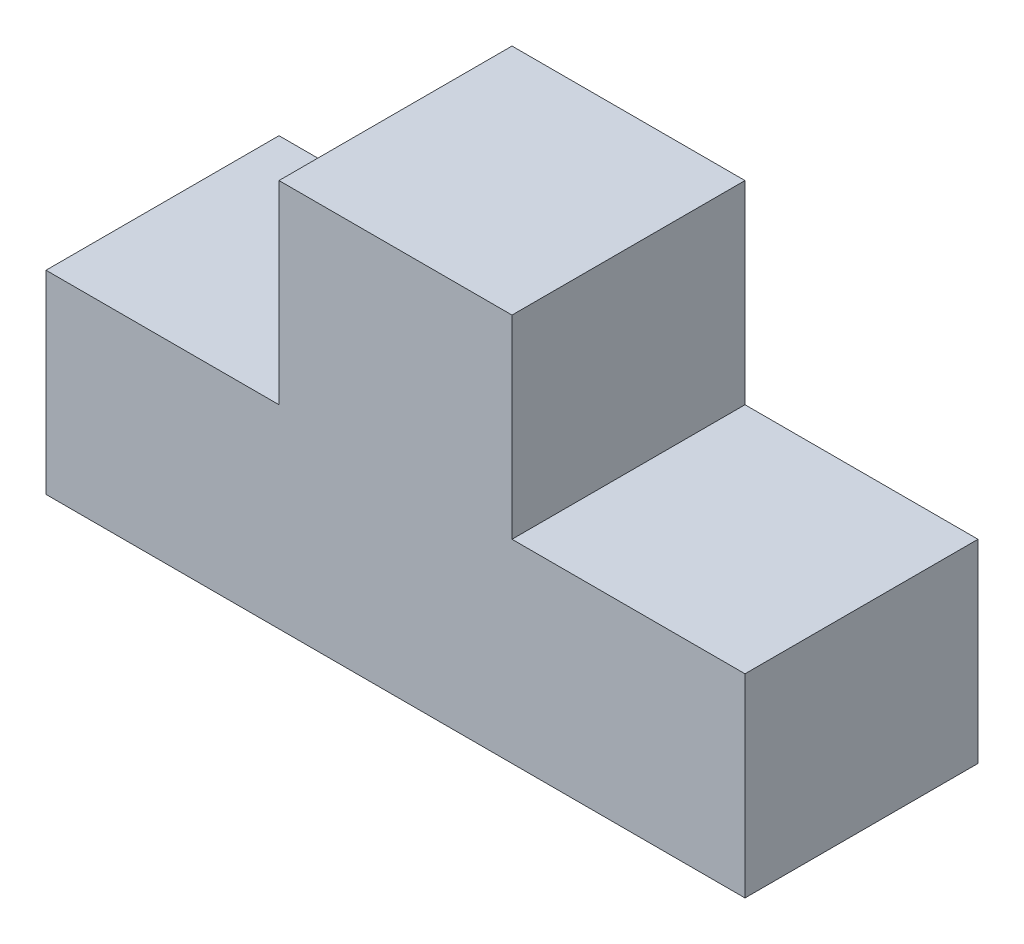
from build123d import *

# Parameters (mm, degrees)
BOSS_EXTRUDE1_DEPTH = 30


with BuildPart() as part:
    # Sketch1 → Boss-Extrude1 (new body)
    with BuildSketch(Plane.XY):
        Polygon((0, 0), (90, 0), (90, 25), (60, 25), (60, 50), (30, 50), (30, 25), (0, 25), align=None)
    extrude(amount=BOSS_EXTRUDE1_DEPTH)


solid = part.part
